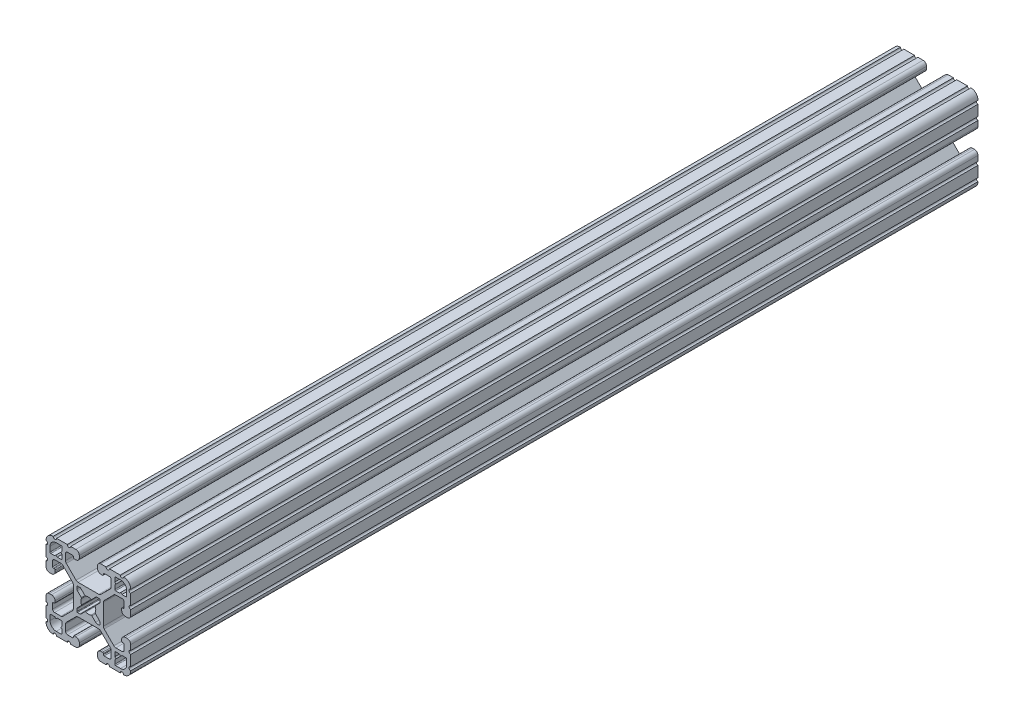
from build123d import *

# Parameters (mm, degrees)
EXTRUDE1_DEPTH = 381


with BuildPart() as part:
    # Sketch1 → Extrude1 (new body)
    with BuildSketch(Plane.XY):
        with BuildLine():
            Line((6.349777007, -14.984831919), (5.653061318, -14.984831848))
            ThreePointArc((5.653061318, -14.984831848), (4.539002167, -15.446080098), (4.077754017, -16.560139291))
            Line((4.077754017, -16.560139291), (4.077753935, -17.474692556))
            ThreePointArc((4.077753935, -17.474692556), (4.539002158, -18.588751741), (5.653061362, -19.049999918))
            Line((5.653061362, -19.049999918), (7.975599859, -19.05))
            ThreePointArc((7.975599859, -19.05), (8.737599929, -18.288), (9.4996, -19.05))
            Line((9.4996, -19.05), (14.298091988, -19.05))
            ThreePointArc((14.298091988, -19.05), (15.05987163, -18.288000032), (15.822092002, -19.049559142))
            ThreePointArc((15.822092002, -19.049559142), (18.110316678, -18.129769245), (19.049898398, -15.849599993))
            ThreePointArc((19.049898398, -15.849599993), (18.288000002, -15.087549199), (19.05, -14.3256))
            Line((19.05, -14.3256), (19.05, -9.499600141))
            ThreePointArc((19.05, -9.499600141), (18.288, -8.737600071), (19.05, -7.9756))
            Line((19.05, -7.9756), (19.05, -5.653061359))
            ThreePointArc((19.05, -5.653061359), (18.588751763, -4.53900218), (17.474692553, -4.077754017))
            Line((17.474692553, -4.077754017), (16.560139293, -4.077753935))
            ThreePointArc((16.560139293, -4.077753935), (15.446080122, -4.539002143), (14.98483193, -5.653061321))
            Line((14.98483193, -5.653061321), (14.984831848, -6.349776986))
            ThreePointArc((14.984831848, -6.349776986), (15.096428348, -6.619420887), (15.366075744, -6.731008942))
            Line((15.366075744, -6.731008942), (15.696937609, -6.730998691))
            ThreePointArc((15.696937609, -6.730998691), (15.966583472, -6.842585282), (16.078181438, -7.112226438))
            Line((16.078181438, -7.112226438), (16.078207121, -9.396837814))
            ThreePointArc((16.078207121, -9.396837814), (15.817838504, -10.026619018), (15.188068118, -10.287013801))
            Line((15.188068118, -10.287013801), (12.352560476, -10.287103022))
            ThreePointArc((12.352560476, -10.287103022), (11.865894357, -10.190173629), (11.453520834, -9.914153164))
            Line((11.453520834, -9.914153164), (7.114725376, -5.565926641))
            ThreePointArc((7.114725376, -5.565926641), (6.840134749, -5.154247475), (6.7437254, -4.668876499))
            Line((6.7437254, -4.668876499), (6.7437254, 4.641368628))
            ThreePointArc((6.7437254, 4.641368628), (6.840134749, 5.126739605), (7.114725376, 5.53841877))
            Line((7.114725376, 5.53841877), (11.480968187, 9.914152308))
            ThreePointArc((11.480968187, 9.914152308), (11.89334171, 10.190172773), (12.380007829, 10.287102166))
            Line((12.380007829, 10.287102166), (15.188068116, 10.287014567))
            ThreePointArc((15.188068116, 10.287014567), (15.817838279, 10.026619243), (16.078206356, 9.396837815))
            Line((16.078206356, 9.396837815), (16.078181509, 7.1122265))
            ThreePointArc((16.078181509, 7.1122265), (15.966583514, 6.842585324), (15.696937607, 6.730998762))
            Line((15.696937607, 6.730998762), (15.366075744, 6.731009012))
            ThreePointArc((15.366075744, 6.731009012), (15.096428376, 6.619420915), (14.984831919, 6.349777007))
            Line((14.984831919, 6.349777007), (14.984831848, 5.653061318))
            ThreePointArc((14.984831848, 5.653061318), (15.446080098, 4.539002167), (16.560139291, 4.077754017))
            Line((16.560139291, 4.077754017), (17.474692556, 4.077753935))
            ThreePointArc((17.474692556, 4.077753935), (18.588751741, 4.539002158), (19.049999918, 5.653061362))
            Line((19.049999918, 5.653061362), (19.05, 7.975599859))
            ThreePointArc((19.05, 7.975599859), (18.288, 8.737599929), (19.05, 9.4996))
            Line((19.05, 9.4996), (19.05, 14.298091988))
            ThreePointArc((19.05, 14.298091988), (18.288000032, 15.05987163), (19.049559142, 15.822092002))
            ThreePointArc((19.049559142, 15.822092002), (18.129769245, 18.110316678), (15.849599993, 19.049898398))
            ThreePointArc((15.849599993, 19.049898398), (15.087549199, 18.288000002), (14.3256, 19.05))
            Line((14.3256, 19.05), (9.499600141, 19.05))
            ThreePointArc((9.499600141, 19.05), (8.737600071, 18.288), (7.9756, 19.05))
            Line((7.9756, 19.05), (5.653061359, 19.05))
            ThreePointArc((5.653061359, 19.05), (4.53900218, 18.588751763), (4.077754017, 17.474692553))
            Line((4.077754017, 17.474692553), (4.077753935, 16.560139293))
            ThreePointArc((4.077753935, 16.560139293), (4.539002143, 15.446080122), (5.653061321, 14.98483193))
            Line((5.653061321, 14.98483193), (6.349776986, 14.984831848))
            ThreePointArc((6.349776986, 14.984831848), (6.619420887, 15.096428348), (6.731008942, 15.366075744))
            Line((6.731008942, 15.366075744), (6.730998691, 15.696937609))
            ThreePointArc((6.730998691, 15.696937609), (6.842585282, 15.966583472), (7.112226438, 16.078181438))
            Line((7.112226438, 16.078181438), (9.396837814, 16.078207121))
            ThreePointArc((9.396837814, 16.078207121), (10.026619018, 15.817838504), (10.287013801, 15.188068118))
            Line((10.287013801, 15.188068118), (10.287103022, 12.352560476))
            ThreePointArc((10.287103022, 12.352560476), (10.190173629, 11.865894357), (9.914153164, 11.453520834))
            Line((9.914153164, 11.453520834), (5.565926641, 7.114725376))
            ThreePointArc((5.565926641, 7.114725376), (5.154247475, 6.840134749), (4.668876499, 6.7437254))
            Line((4.668876499, 6.7437254), (-4.641368628, 6.7437254))
            ThreePointArc((-4.641368628, 6.7437254), (-5.126739605, 6.840134749), (-5.53841877, 7.114725376))
            Line((-5.53841877, 7.114725376), (-9.914152308, 11.480968187))
            ThreePointArc((-9.914152308, 11.480968187), (-10.190172773, 11.89334171), (-10.287102166, 12.380007829))
            Line((-10.287102166, 12.380007829), (-10.287014567, 15.188068116))
            ThreePointArc((-10.287014567, 15.188068116), (-10.026619243, 15.817838279), (-9.396837815, 16.078206356))
            Line((-9.396837815, 16.078206356), (-7.1122265, 16.078181509))
            ThreePointArc((-7.1122265, 16.078181509), (-6.842585324, 15.966583514), (-6.730998762, 15.696937607))
            Line((-6.730998762, 15.696937607), (-6.731008942, 15.366075744))
            ThreePointArc((-6.731008942, 15.366075744), (-6.619420905, 15.096428366), (-6.349777007, 14.984831919))
            Line((-6.349777007, 14.984831919), (-5.653061318, 14.984831848))
            ThreePointArc((-5.653061318, 14.984831848), (-4.539002167, 15.446080098), (-4.077754017, 16.560139291))
            Line((-4.077754017, 16.560139291), (-4.077753935, 17.474692556))
            ThreePointArc((-4.077753935, 17.474692556), (-4.539002158, 18.588751741), (-5.653061362, 19.049999918))
            Line((-5.653061362, 19.049999918), (-7.975599859, 19.05))
            ThreePointArc((-7.975599859, 19.05), (-8.737599929, 18.288), (-9.4996, 19.05))
            Line((-9.4996, 19.05), (-14.298091988, 19.05))
            ThreePointArc((-14.298091988, 19.05), (-15.05987163, 18.288000032), (-15.822092002, 19.049559142))
            ThreePointArc((-15.822092002, 19.049559142), (-18.110316678, 18.129769245), (-19.049898398, 15.849599993))
            ThreePointArc((-19.049898398, 15.849599993), (-18.288000002, 15.087549199), (-19.05, 14.3256))
            Line((-19.05, 14.3256), (-19.05, 9.499600141))
            ThreePointArc((-19.05, 9.499600141), (-18.288, 8.737600071), (-19.05, 7.9756))
            Line((-19.05, 7.9756), (-19.05, 5.653061359))
            ThreePointArc((-19.05, 5.653061359), (-18.588751763, 4.53900218), (-17.474692553, 4.077754017))
            Line((-17.474692553, 4.077754017), (-16.560139293, 4.077753935))
            ThreePointArc((-16.560139293, 4.077753935), (-15.446080122, 4.539002143), (-14.98483193, 5.653061321))
            Line((-14.98483193, 5.653061321), (-14.984831848, 6.349776986))
            ThreePointArc((-14.984831848, 6.349776986), (-15.096428348, 6.619420887), (-15.366075744, 6.731008942))
            Line((-15.366075744, 6.731008942), (-15.696937609, 6.730998691))
            ThreePointArc((-15.696937609, 6.730998691), (-15.966583472, 6.842585283), (-16.078181438, 7.112226438))
            Line((-16.078181438, 7.112226438), (-16.078207121, 9.396837814))
            ThreePointArc((-16.078207121, 9.396837814), (-15.817838504, 10.026619018), (-15.188068118, 10.287013802))
            Line((-15.188068118, 10.287013802), (-12.352560476, 10.287103022))
            ThreePointArc((-12.352560476, 10.287103022), (-11.865894357, 10.190173629), (-11.453520834, 9.914153164))
            Line((-11.453520834, 9.914153164), (-7.114725376, 5.565926641))
            ThreePointArc((-7.114725376, 5.565926641), (-6.840134749, 5.154247475), (-6.7437254, 4.668876499))
            Line((-6.7437254, 4.668876499), (-6.7437254, -4.641368628))
            ThreePointArc((-6.7437254, -4.641368628), (-6.840134749, -5.126739605), (-7.114725376, -5.53841877))
            Line((-7.114725376, -5.53841877), (-11.480968187, -9.914152308))
            ThreePointArc((-11.480968187, -9.914152308), (-11.89334171, -10.190172773), (-12.380007829, -10.287102166))
            Line((-12.380007829, -10.287102166), (-15.188068116, -10.287014567))
            ThreePointArc((-15.188068116, -10.287014567), (-15.817838279, -10.026619243), (-16.078206356, -9.396837815))
            Line((-16.078206356, -9.396837815), (-16.078181509, -7.1122265))
            ThreePointArc((-16.078181509, -7.1122265), (-15.966583514, -6.842585324), (-15.696937607, -6.730998762))
            Line((-15.696937607, -6.730998762), (-15.366075744, -6.731009012))
            ThreePointArc((-15.366075744, -6.731009012), (-15.096428376, -6.619420915), (-14.984831919, -6.349777007))
            Line((-14.984831919, -6.349777007), (-14.984831848, -5.653061318))
            ThreePointArc((-14.984831848, -5.653061318), (-15.446080098, -4.539002167), (-16.560139291, -4.077754017))
            Line((-16.560139291, -4.077754017), (-17.474692556, -4.077753935))
            ThreePointArc((-17.474692556, -4.077753935), (-18.588751741, -4.539002158), (-19.049999918, -5.653061362))
            Line((-19.049999918, -5.653061362), (-19.05, -7.975599859))
            ThreePointArc((-19.05, -7.975599859), (-18.288, -8.737599929), (-19.05, -9.4996))
            Line((-19.05, -9.4996), (-19.05, -14.298091988))
            ThreePointArc((-19.05, -14.298091988), (-18.288000032, -15.05987163), (-19.049559142, -15.822092002))
            ThreePointArc((-19.049559142, -15.822092002), (-18.129769245, -18.110316678), (-15.849599993, -19.049898398))
            ThreePointArc((-15.849599993, -19.049898398), (-15.087549199, -18.288000002), (-14.3256, -19.05))
            Line((-14.3256, -19.05), (-9.499600141, -19.05))
            ThreePointArc((-9.499600141, -19.05), (-8.737600071, -18.288), (-7.9756, -19.05))
            Line((-7.9756, -19.05), (-5.653061359, -19.05))
            ThreePointArc((-5.653061359, -19.05), (-4.53900218, -18.588751763), (-4.077754017, -17.474692553))
            Line((-4.077754017, -17.474692553), (-4.077753935, -16.560139293))
            ThreePointArc((-4.077753935, -16.560139293), (-4.539002143, -15.446080122), (-5.653061321, -14.98483193))
            Line((-5.653061321, -14.98483193), (-6.349776986, -14.984831848))
            ThreePointArc((-6.349776986, -14.984831848), (-6.619420887, -15.096428348), (-6.731008942, -15.366075744))
            Line((-6.731008942, -15.366075744), (-6.730998691, -15.696937609))
            ThreePointArc((-6.730998691, -15.696937609), (-6.842585282, -15.966583472), (-7.112226438, -16.078181438))
            Line((-7.112226438, -16.078181438), (-9.396837814, -16.078207121))
            ThreePointArc((-9.396837814, -16.078207121), (-10.026619018, -15.817838504), (-10.287013801, -15.188068118))
            Line((-10.287013801, -15.188068118), (-10.287103022, -12.352560476))
            ThreePointArc((-10.287103022, -12.352560476), (-10.190173629, -11.865894357), (-9.914153164, -11.453520834))
            Line((-9.914153164, -11.453520834), (-5.565926641, -7.114725376))
            ThreePointArc((-5.565926641, -7.114725376), (-5.154247475, -6.840134749), (-4.668876499, -6.7437254))
            Line((-4.668876499, -6.7437254), (4.641368628, -6.7437254))
            ThreePointArc((4.641368628, -6.7437254), (5.126739605, -6.840134749), (5.53841877, -7.114725376))
            Line((5.53841877, -7.114725376), (9.914152308, -11.480968187))
            ThreePointArc((9.914152308, -11.480968187), (10.190172773, -11.89334171), (10.287102166, -12.380007829))
            Line((10.287102166, -12.380007829), (10.287014567, -15.188068116))
            ThreePointArc((10.287014567, -15.188068116), (10.026619243, -15.817838279), (9.396837815, -16.078206356))
            Line((9.396837815, -16.078206356), (7.1122265, -16.078181509))
            ThreePointArc((7.1122265, -16.078181509), (6.842585324, -15.966583514), (6.730998762, -15.696937607))
            Line((6.730998762, -15.696937607), (6.731008942, -15.366075744))
            ThreePointArc((6.731008942, -15.366075744), (6.619420905, -15.096428366), (6.349777007, -14.984831919))
        make_face()
        with BuildLine():
            Line((1.582347442, 3.198793543), (3.292097227, 4.908543328))
            ThreePointArc((3.292097227, 4.908543328), (3.580509584, 5.101254304), (3.920715155, 5.1689254))
            Line((3.920715155, 5.1689254), (4.9149254, 5.1689254))
            ThreePointArc((4.9149254, 5.1689254), (5.094530522, 5.094530522), (5.1689254, 4.9149254))
            Line((5.1689254, 4.9149254), (5.1689254, 3.920715155))
            ThreePointArc((5.1689254, 3.920715155), (5.101254304, 3.580509584), (4.908543328, 3.292097227))
            Line((4.908543328, 3.292097227), (3.198793543, 1.582347442))
            ThreePointArc((3.198793543, 1.582347442), (3.095711236, 1.393016011), (3.111879183, 1.178048687))
            ThreePointArc((3.111879183, 1.178048687), (3.3274, 0), (3.111879183, -1.178048687))
            ThreePointArc((3.111879183, -1.178048687), (3.095711236, -1.393016011), (3.198793543, -1.582347442))
            Line((3.198793543, -1.582347442), (4.908543328, -3.292097227))
            ThreePointArc((4.908543328, -3.292097227), (5.101254304, -3.580509584), (5.1689254, -3.920715155))
            Line((5.1689254, -3.920715155), (5.1689254, -4.9149254))
            ThreePointArc((5.1689254, -4.9149254), (5.094530522, -5.094530522), (4.9149254, -5.1689254))
            Line((4.9149254, -5.1689254), (3.920715155, -5.1689254))
            ThreePointArc((3.920715155, -5.1689254), (3.580509584, -5.101254304), (3.292097227, -4.908543328))
            Line((3.292097227, -4.908543328), (1.582347442, -3.198793543))
            ThreePointArc((1.582347442, -3.198793543), (1.393016011, -3.095711236), (1.178048687, -3.111879183))
            ThreePointArc((1.178048687, -3.111879183), (0, -3.3274), (-1.178048687, -3.111879183))
            ThreePointArc((-1.178048687, -3.111879183), (-1.393016011, -3.095711236), (-1.582347442, -3.198793543))
            Line((-1.582347442, -3.198793543), (-3.292097227, -4.908543328))
            ThreePointArc((-3.292097227, -4.908543328), (-3.580509584, -5.101254304), (-3.920715155, -5.1689254))
            Line((-3.920715155, -5.1689254), (-4.9149254, -5.1689254))
            ThreePointArc((-4.9149254, -5.1689254), (-5.094530522, -5.094530522), (-5.1689254, -4.9149254))
            Line((-5.1689254, -4.9149254), (-5.1689254, -3.920715155))
            ThreePointArc((-5.1689254, -3.920715155), (-5.101254304, -3.580509584), (-4.908543328, -3.292097227))
            Line((-4.908543328, -3.292097227), (-3.198793543, -1.582347442))
            ThreePointArc((-3.198793543, -1.582347442), (-3.095711236, -1.393016011), (-3.111879183, -1.178048687))
            ThreePointArc((-3.111879183, -1.178048687), (-3.3274, 0), (-3.111879183, 1.178048687))
            ThreePointArc((-3.111879183, 1.178048687), (-3.095711236, 1.393016011), (-3.198793543, 1.582347442))
            Line((-3.198793543, 1.582347442), (-4.908543328, 3.292097227))
            ThreePointArc((-4.908543328, 3.292097227), (-5.101254304, 3.580509584), (-5.1689254, 3.920715155))
            Line((-5.1689254, 3.920715155), (-5.1689254, 4.9149254))
            ThreePointArc((-5.1689254, 4.9149254), (-5.094530522, 5.094530522), (-4.9149254, 5.1689254))
            Line((-4.9149254, 5.1689254), (-3.920715155, 5.1689254))
            ThreePointArc((-3.920715155, 5.1689254), (-3.580509584, 5.101254304), (-3.292097227, 4.908543328))
            Line((-3.292097227, 4.908543328), (-1.582347442, 3.198793543))
            ThreePointArc((-1.582347442, 3.198793543), (-1.393016011, 3.095711236), (-1.178048687, 3.111879183))
            ThreePointArc((-1.178048687, 3.111879183), (0, 3.3274), (1.178048687, 3.111879183))
            ThreePointArc((1.178048687, 3.111879183), (1.393016011, 3.095711236), (1.582347442, 3.198793543))
        make_face(mode=Mode.SUBTRACT)
        with BuildLine():
            Line((-11.8669054, 14.019430433), (-11.8669054, 12.24788))
            ThreePointArc((-11.8669054, 12.24788), (-11.978497716, 11.978472316), (-12.2479054, 11.86688))
            Line((-12.2479054, 11.86688), (-14.019455833, 11.86688))
            ThreePointArc((-14.019455833, 11.86688), (-14.020427836, 11.867073341), (-14.021251865, 11.867623929))
            Line((-14.021251865, 11.867623929), (-14.557512425, 12.403872831))
            ThreePointArc((-14.557512425, 12.403872831), (-14.559308484, 12.404616761), (-14.561104527, 12.403872792))
            Line((-14.561104527, 12.403872792), (-15.097341694, 11.867623968))
            ThreePointArc((-15.097341694, 11.867623968), (-15.098165736, 11.867073351), (-15.099137765, 11.86688))
            Line((-15.099137765, 11.86688), (-16.8707054, 11.86688))
            ThreePointArc((-16.8707054, 11.86688), (-17.140113084, 11.978472316), (-17.2517054, 12.24788))
            Line((-17.2517054, 12.24788), (-17.2517054, 14.45768))
            ThreePointArc((-17.2517054, 14.45768), (-16.433361747, 16.433336347), (-14.4577054, 17.25168))
            Line((-14.4577054, 17.25168), (-12.2479054, 17.25168))
            ThreePointArc((-12.2479054, 17.25168), (-11.978497716, 17.140087684), (-11.8669054, 16.87068))
            Line((-11.8669054, 16.87068), (-11.8669054, 15.099112365))
            ThreePointArc((-11.8669054, 15.099112365), (-11.867098751, 15.098140336), (-11.867649368, 15.097316294))
            Line((-11.867649368, 15.097316294), (-12.403898192, 14.561079127))
            ThreePointArc((-12.403898192, 14.561079127), (-12.40464216, 14.559283084), (-12.403898231, 14.557487025))
            Line((-12.403898231, 14.557487025), (-11.867649329, 14.021226465))
            ThreePointArc((-11.867649329, 14.021226465), (-11.867098741, 14.020402437), (-11.8669054, 14.019430433))
        make_face(mode=Mode.SUBTRACT)
        with BuildLine():
            Line((-14.019430433, -11.8669054), (-12.24788, -11.8669054))
            ThreePointArc((-12.24788, -11.8669054), (-11.978472316, -11.978497716), (-11.86688, -12.2479054))
            Line((-11.86688, -12.2479054), (-11.86688, -14.019455833))
            ThreePointArc((-11.86688, -14.019455833), (-11.867073341, -14.020427836), (-11.867623929, -14.021251865))
            Line((-11.867623929, -14.021251865), (-12.403872831, -14.557512425))
            ThreePointArc((-12.403872831, -14.557512425), (-12.404616761, -14.559308484), (-12.403872792, -14.561104527))
            Line((-12.403872792, -14.561104527), (-11.867623968, -15.097341694))
            ThreePointArc((-11.867623968, -15.097341694), (-11.867073351, -15.098165736), (-11.86688, -15.099137765))
            Line((-11.86688, -15.099137765), (-11.86688, -16.8707054))
            ThreePointArc((-11.86688, -16.8707054), (-11.978472316, -17.140113083), (-12.24788, -17.2517054))
            Line((-12.24788, -17.2517054), (-14.45768, -17.2517054))
            ThreePointArc((-14.45768, -17.2517054), (-16.433336347, -16.433361746), (-17.25168, -14.4577054))
            Line((-17.25168, -14.4577054), (-17.25168, -12.2479054))
            ThreePointArc((-17.25168, -12.2479054), (-17.140087684, -11.978497716), (-16.87068, -11.8669054))
            Line((-16.87068, -11.8669054), (-15.099112365, -11.8669054))
            ThreePointArc((-15.099112365, -11.8669054), (-15.098140336, -11.867098751), (-15.097316294, -11.867649368))
            Line((-15.097316294, -11.867649368), (-14.561079127, -12.403898192))
            ThreePointArc((-14.561079127, -12.403898192), (-14.559283084, -12.40464216), (-14.557487025, -12.403898231))
            Line((-14.557487025, -12.403898231), (-14.021226465, -11.867649329))
            ThreePointArc((-14.021226465, -11.867649329), (-14.020402437, -11.867098741), (-14.019430433, -11.8669054))
        make_face(mode=Mode.SUBTRACT)
        with BuildLine():
            Line((11.8669054, -14.019430433), (11.8669054, -12.24788))
            ThreePointArc((11.8669054, -12.24788), (11.978497716, -11.978472316), (12.2479054, -11.86688))
            Line((12.2479054, -11.86688), (14.019455833, -11.86688))
            ThreePointArc((14.019455833, -11.86688), (14.020427836, -11.867073341), (14.021251865, -11.867623929))
            Line((14.021251865, -11.867623929), (14.557512425, -12.403872831))
            ThreePointArc((14.557512425, -12.403872831), (14.559308484, -12.404616761), (14.561104527, -12.403872792))
            Line((14.561104527, -12.403872792), (15.097341694, -11.867623968))
            ThreePointArc((15.097341694, -11.867623968), (15.098165736, -11.867073351), (15.099137765, -11.86688))
            Line((15.099137765, -11.86688), (16.8707054, -11.86688))
            ThreePointArc((16.8707054, -11.86688), (17.140113084, -11.978472316), (17.2517054, -12.24788))
            Line((17.2517054, -12.24788), (17.2517054, -14.45768))
            ThreePointArc((17.2517054, -14.45768), (16.433361747, -16.433336347), (14.4577054, -17.25168))
            Line((14.4577054, -17.25168), (12.2479054, -17.25168))
            ThreePointArc((12.2479054, -17.25168), (11.978497716, -17.140087684), (11.8669054, -16.87068))
            Line((11.8669054, -16.87068), (11.8669054, -15.099112365))
            ThreePointArc((11.8669054, -15.099112365), (11.867098751, -15.098140336), (11.867649368, -15.097316294))
            Line((11.867649368, -15.097316294), (12.403898192, -14.561079127))
            ThreePointArc((12.403898192, -14.561079127), (12.40464216, -14.559283084), (12.403898231, -14.557487025))
            Line((12.403898231, -14.557487025), (11.867649329, -14.021226465))
            ThreePointArc((11.867649329, -14.021226465), (11.867098741, -14.020402436), (11.8669054, -14.019430433))
        make_face(mode=Mode.SUBTRACT)
        with BuildLine():
            Line((14.019430433, 11.8669054), (12.24788, 11.8669054))
            ThreePointArc((12.24788, 11.8669054), (11.978472316, 11.978497716), (11.86688, 12.2479054))
            Line((11.86688, 12.2479054), (11.86688, 14.019455833))
            ThreePointArc((11.86688, 14.019455833), (11.867073341, 14.020427836), (11.867623929, 14.021251865))
            Line((11.867623929, 14.021251865), (12.403872831, 14.557512425))
            ThreePointArc((12.403872831, 14.557512425), (12.404616761, 14.559308484), (12.403872792, 14.561104527))
            Line((12.403872792, 14.561104527), (11.867623968, 15.097341694))
            ThreePointArc((11.867623968, 15.097341694), (11.867073351, 15.098165736), (11.86688, 15.099137765))
            Line((11.86688, 15.099137765), (11.86688, 16.8707054))
            ThreePointArc((11.86688, 16.8707054), (11.978472316, 17.140113084), (12.24788, 17.2517054))
            Line((12.24788, 17.2517054), (14.45768, 17.2517054))
            ThreePointArc((14.45768, 17.2517054), (16.433336347, 16.433361747), (17.25168, 14.4577054))
            Line((17.25168, 14.4577054), (17.25168, 12.2479054))
            ThreePointArc((17.25168, 12.2479054), (17.140087684, 11.978497716), (16.87068, 11.8669054))
            Line((16.87068, 11.8669054), (15.099112365, 11.8669054))
            ThreePointArc((15.099112365, 11.8669054), (15.098140336, 11.867098751), (15.097316294, 11.867649368))
            Line((15.097316294, 11.867649368), (14.561079127, 12.403898192))
            ThreePointArc((14.561079127, 12.403898192), (14.559283084, 12.404642161), (14.557487025, 12.403898231))
            Line((14.557487025, 12.403898231), (14.021226465, 11.867649329))
            ThreePointArc((14.021226465, 11.867649329), (14.020402436, 11.867098741), (14.019430433, 11.8669054))
        make_face(mode=Mode.SUBTRACT)
    extrude(amount=-EXTRUDE1_DEPTH)


solid = part.part
